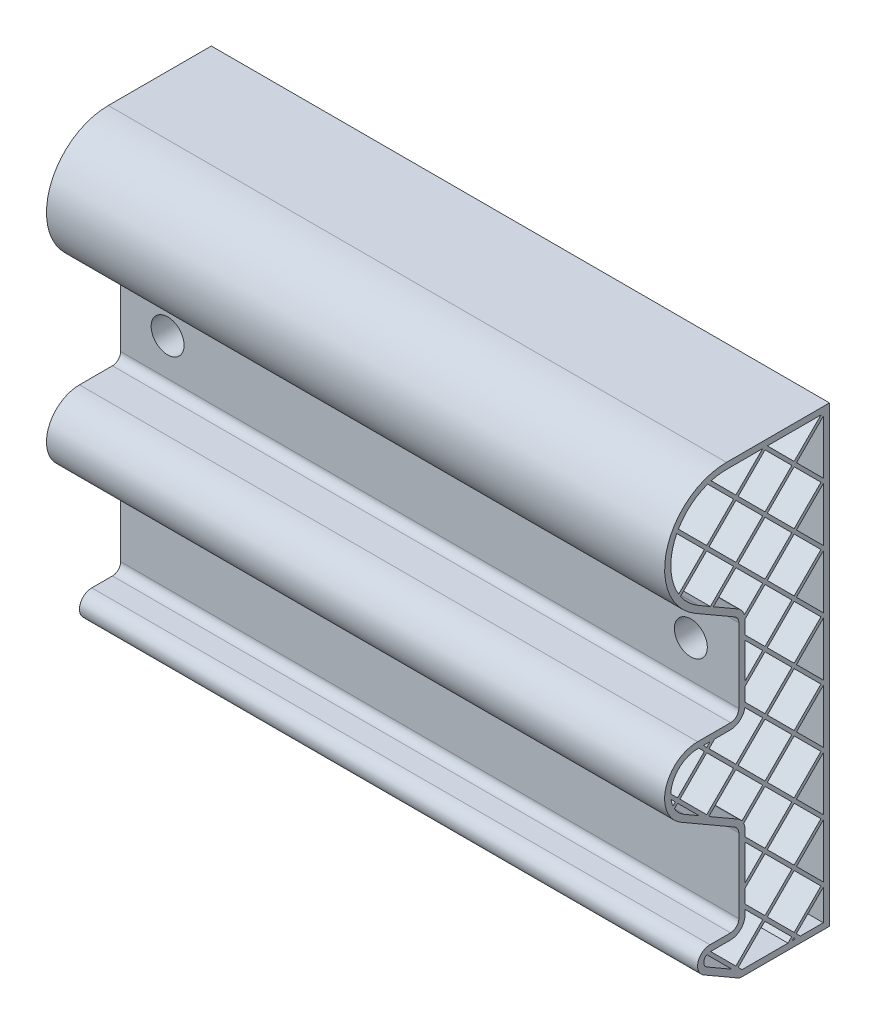
from build123d import *

# Parameters (mm, degrees)
SALIENTE_EXTRUIR1_DEPTH = 150
CORTAR_EXTRUIR1_DEPTH   = 151
CROQUIS6_R              = 5
SALIENTE_EXTRUIR2_DEPTH = 22
CROQUIS6_3_R            = 5
SALIENTE_EXTRUIR3_DEPTH = 22
CROQUIS7_R              = 2.5
CROQUIS7_R_2            = 2.567013522
CORTAR_EXTRUIR2_DEPTH   = 22
CROQUIS8_R              = 4
CORTAR_EXTRUIR3_DEPTH   = 7
CORTAR_EXTRUIR4_DEPTH   = 0.5


with BuildPart() as part:
    # Croquis1 → Saliente-Extruir1 (new body)
    with BuildSketch(Plane(origin=(0, 0, 0), x_dir=(0, 0, -1), z_dir=(1, 0, 0))):
        with BuildLine():
            Line((0, 0), (-21.253866082, 0))
            ThreePointArc((-21.253866082, 0), (-21.771504172, 0.068148347), (-22.253866082, 0.267949192))
            Line((-22.253866082, 0.267949192), (-30.5, 5.02885683))
            ThreePointArc((-30.5, 5.02885683), (-31.897777479, 8.403390176), (-29, 10.626933041))
            Line((-29, 10.626933041), (-24, 10.626933041))
            ThreePointArc((-24, 10.626933041), (-22.585786438, 11.212719479), (-22, 12.626933041))
            Line((-22, 12.626933041), (-22, 30.626933041))
            ThreePointArc((-22, 30.626933041), (-22.267949192, 31.626933041), (-23, 32.358983849))
            Line((-23, 32.358983849), (-36, 39.864537348))
            ThreePointArc((-36, 39.864537348), (-39.72740661, 48.863292939), (-32, 54.792740578))
            Line((-32, 54.792740578), (-24, 54.792740578))
            ThreePointArc((-24, 54.792740578), (-22.585786438, 55.378527016), (-22, 56.792740578))
            Line((-22, 56.792740578), (-22, 74.792740578))
            ThreePointArc((-22, 74.792740578), (-22.267949192, 75.792740578), (-23, 76.524791386))
            Line((-23, 76.524791386), (-32.5, 82.009618943))
            ThreePointArc((-32.5, 82.009618943), (-39.488887394, 98.882285677), (-25, 110))
            Line((-25, 110), (0, 110))
            Line((0, 110), (0, 0))
        make_face()
    extrude(amount=SALIENTE_EXTRUIR1_DEPTH)

    # Croquis5 → Cortar-Extruir1 (cut, through all)
    with BuildSketch(Plane(origin=(150, 0, 0), x_dir=(0, 0, -1), z_dir=(1, 0, 0))):
        with BuildLine():
            Line((-29.75, 6.327894935), (-23.652281634, 2.807375595))
            Line((-23.652281634, 2.807375595), (-29.763178762, 8.918272724))
            ThreePointArc((-29.763178762, 8.918272724), (-30.499980588, 7.619301765), (-29.75, 6.327894935))
        make_face()
        with BuildLine():
            Line((-20.5, 30.626933041), (-20.5, 29.070736059))
            Line((-20.5, 29.070736059), (-15.642135624, 24.212871683))
            Line((-15.642135624, 24.212871683), (-9.136753237, 30.718254069))
            Line((-9.136753237, 30.718254069), (-15.642135624, 37.223636456))
            Line((-15.642135624, 37.223636456), (-20.80650404, 32.059268041))
            ThreePointArc((-20.80650404, 32.059268041), (-20.577483684, 31.359314137), (-20.5, 30.626933041))
        make_face()
        Polygon((-10.070736059, 1.5), (-9.171921728, 2.398814331), (-15.677304115, 8.904196718), (-22.147518011, 2.433982822), (-21.213535189, 1.5), align=None)
        with BuildLine():
            Line((-22.713203436, 2.999668247), (-16.207821049, 9.505050634))
            Line((-16.207821049, 9.505050634), (-20.5, 13.797229585))
            Line((-20.5, 13.797229585), (-20.5, 12.626933041))
            ThreePointArc((-20.5, 12.626933041), (-21.525126266, 10.152059307), (-24, 9.126933041))
            Line((-24, 9.126933041), (-28.84046823, 9.126933041))
            Line((-28.84046823, 9.126933041), (-22.713203436, 2.999668247))
        make_face()
        Polygon((-7.071399565, 1.5), (-8.049919447, 2.478519882), (-1.5, 8.939365209), (-1.5, 1.5), align=None)
        Polygon((-2.065685425, 9.505050634), (-8.571067812, 16.010433021), (-15.076450199, 9.505050634), (-8.571067812, 2.999668247), align=None)
        Polygon((-1.5, 10.070736059), (-8.005382387, 16.576118446), (-1.5, 23.081500833), align=None)
        Polygon((-2.065685425, 23.647186258), (-8.571067812, 30.152568645), (-15.076450199, 23.647186258), (-8.571067812, 17.141803871), align=None)
        Polygon((-1.5, 24.212871683), (-8.005382387, 30.718254069), (-1.5, 37.223636456), align=None)
        Polygon((-2.065685425, 37.789321881), (-8.571067812, 44.294704268), (-15.076450199, 37.789321881), (-8.571067812, 31.283939494), align=None)
        Polygon((-1.5, 38.355007306), (-8.005382387, 44.860389693), (-1.5, 51.36577208), align=None)
        Polygon((-29.784271247, 38.355007306), (-23.278888861, 44.860389693), (-29.784271247, 51.36577208), (-36.289653634, 44.860389693), align=None)
        with BuildLine():
            Line((-29.218585823, 37.789321881), (-22.713203436, 44.294704268))
            Line((-22.713203436, 44.294704268), (-16.207821049, 37.789321881))
            Line((-16.207821049, 37.789321881), (-21.230346076, 32.766796854))
            ThreePointArc((-21.230346076, 32.766796854), (-21.696657115, 33.262196132), (-22.25, 33.658021954))
            Line((-22.25, 33.658021954), (-28.963090506, 37.533826565))
            Line((-28.963090506, 37.533826565), (-29.218585823, 37.789321881))
        make_face()
        Polygon((-1.5, 52.49714293), (-8.005382387, 59.002525317), (-1.5, 65.507907704), align=None)
        Polygon((-2.065685425, 51.931457505), (-8.571067812, 58.436839892), (-15.076450199, 51.931457505), (-8.571067812, 45.426075118), align=None)
        with BuildLine():
            Line((-37.621148526, 43.528894802), (-36.855339059, 44.294704268))
            Line((-36.855339059, 44.294704268), (-31.639942678, 39.079307887))
            Line((-31.639942678, 39.079307887), (-35.25, 41.163575454))
            ThreePointArc((-35.25, 41.163575454), (-36.590534059, 42.190893443), (-37.621148526, 43.528894802))
        make_face()
        with BuildLine():
            Line((-37.996664295, 44.284749882), (-37.421024484, 44.860389693))
            Line((-37.421024484, 44.860389693), (-38.434760865, 45.874126074))
            ThreePointArc((-38.434760865, 45.874126074), (-38.266307689, 45.065491913), (-37.996664295, 44.284749882))
        make_face()
        Polygon((-20.5, 74.792178951), (-15.642135624, 79.650043328), (-9.136753237, 73.144660941), (-15.642135624, 66.639278554), (-20.5, 71.49714293), align=None)
        with BuildLine():
            Line((-20.642449535, 75.781100266), (-16.207821049, 80.215728753))
            Line((-16.207821049, 80.215728753), (-22.713203436, 86.721111139))
            Line((-22.713203436, 86.721111139), (-28.184309751, 81.250004824))
            Line((-28.184309751, 81.250004824), (-22.25, 77.823829492))
            ThreePointArc((-22.25, 77.823829492), (-21.249553925, 76.957237377), (-20.642449535, 75.781100266))
        make_face()
        Polygon((-1.5, 107.934314575), (-8.005382387, 101.428932188), (-1.5, 94.923549801), align=None)
        Polygon((-2.065685425, 108.5), (-8.571067812, 101.994617613), (-15.076450199, 108.5), align=None)
        Polygon((-15.642135624, 107.934314575), (-9.136753237, 101.428932188), (-15.642135624, 94.923549801), (-22.147518011, 101.428932188), align=None)
        with BuildLine():
            Line((-36.165178282, 87.411271917), (-29.784271247, 93.792178951))
            Line((-29.784271247, 93.792178951), (-23.278888861, 87.286796564))
            Line((-23.278888861, 87.286796564), (-28.901570129, 81.664115296))
            Line((-28.901570129, 81.664115296), (-31.75, 83.308657049))
            ThreePointArc((-31.75, 83.308657049), (-34.189464914, 85.110422932), (-36.165178282, 87.411271917))
        make_face()
        with BuildLine():
            Line((-36.605078302, 88.102742747), (-30.349956672, 94.357864376))
            Line((-30.349956672, 94.357864376), (-37.059638564, 101.067546268))
            ThreePointArc((-37.059638564, 101.067546268), (-38.491709998, 94.526965818), (-36.605078302, 88.102742747))
        make_face()
        with BuildLine():
            Line((-36.661739101, 101.801017655), (-29.784271247, 94.923549801))
            Line((-29.784271247, 94.923549801), (-23.278888861, 101.428932188))
            Line((-23.278888861, 101.428932188), (-29.557428651, 107.707471979))
            ThreePointArc((-29.557428651, 107.707471979), (-33.630579431, 105.380900668), (-36.661739101, 101.801017655))
        make_face()
        with BuildLine():
            Line((-28.701285342, 107.98269952), (-22.713203436, 101.994617613))
            Line((-22.713203436, 101.994617613), (-16.207821049, 108.5))
            Line((-16.207821049, 108.5), (-25, 108.5))
            ThreePointArc((-25, 108.5), (-26.868630044, 108.37004943), (-28.701285342, 107.98269952))
        make_face()
        Polygon((-22.713203436, 100.863246763), (-16.207821049, 94.357864376), (-22.713203436, 87.852481989), (-29.218585823, 94.357864376), align=None)
        Polygon((-15.076450199, 94.357864376), (-8.571067812, 87.852481989), (-2.065685425, 94.357864376), (-8.571067812, 100.863246763), align=None)
        Polygon((-15.642135624, 93.792178951), (-22.147518011, 87.286796564), (-15.642135624, 80.781414177), (-9.136753237, 87.286796564), align=None)
        Polygon((-8.005382387, 87.286796564), (-1.5, 80.781414177), (-1.5, 93.792178951), align=None)
        Polygon((-8.571067812, 86.721111139), (-2.065685425, 80.215728753), (-8.571067812, 73.710346366), (-15.076450199, 80.215728753), align=None)
        Polygon((-8.571067812, 72.578975516), (-2.065685425, 66.073593129), (-8.571067812, 59.568210742), (-15.076450199, 66.073593129), align=None)
        Polygon((-8.005382387, 73.144660941), (-1.5, 66.639278554), (-1.5, 79.650043328), align=None)
        Polygon((-16.207821049, 66.073593129), (-20.5, 70.36577208), (-20.5, 61.781414177), align=None)
        Polygon((-9.136753237, 59.002525317), (-15.642135624, 65.507907704), (-20.5, 60.650043328), (-20.5, 57.355007306), (-15.642135624, 52.49714293), align=None)
        with BuildLine():
            Line((-16.207821049, 51.931457505), (-20.540194436, 56.263830892))
            ThreePointArc((-20.540194436, 56.263830892), (-21.719778947, 54.1374455), (-24, 53.292740578))
            Line((-24, 53.292740578), (-27.857302749, 53.292740578))
            Line((-27.857302749, 53.292740578), (-29.218585823, 51.931457505))
            Line((-29.218585823, 51.931457505), (-22.713203436, 45.426075118))
            Line((-22.713203436, 45.426075118), (-16.207821049, 51.931457505))
        make_face()
        Polygon((-29.784271247, 52.49714293), (-28.988673599, 53.292740578), (-30.579868896, 53.292740578), align=None)
        with BuildLine():
            Line((-30.349956672, 51.931457505), (-31.711239746, 53.292740578))
            Line((-31.711239746, 53.292740578), (-32, 53.292740578))
            ThreePointArc((-32, 53.292740578), (-36.498895226, 51.484216012), (-38.494294287, 47.065030346))
            Line((-38.494294287, 47.065030346), (-36.855339059, 45.426075118))
            Line((-36.855339059, 45.426075118), (-30.349956672, 51.931457505))
        make_face()
        Polygon((-15.642135624, 38.355007306), (-9.136753237, 44.860389693), (-15.642135624, 51.36577208), (-22.147518011, 44.860389693), align=None)
        Polygon((-16.207821049, 23.647186258), (-20.5, 27.939365209), (-20.5, 19.355007306), align=None)
        Polygon((-9.136753237, 16.576118446), (-15.642135624, 23.081500833), (-20.5, 18.223636456), (-20.5, 14.928600435), (-15.642135624, 10.070736059), align=None)
        Polygon((-8.654886921, 1.881779524), (-8.273107397, 1.5), (-9.041929948, 1.5), align=None)
    extrude(amount=-CORTAR_EXTRUIR1_DEPTH, mode=Mode.SUBTRACT)

    # Croquis6 → Saliente-Extruir2 (add)
    with BuildSketch(Plane.XY.offset(22)):
        with Locations((11.391749044, 65.792740578)):
            Circle(CROQUIS6_R)
    extrude(amount=-SALIENTE_EXTRUIR2_DEPTH)

    # Croquis6_3 → Saliente-Extruir3 (add)
    with BuildSketch(Plane.XY.offset(22)):
        with Locations((138.359294984, 65.792740578)):
            Circle(CROQUIS6_3_R)
    extrude(amount=-SALIENTE_EXTRUIR3_DEPTH)

    # Croquis7 → Cortar-Extruir2 (cut)
    with BuildSketch(Plane.XY.offset(22)):
        with Locations((11.391749044, 65.792740578)):
            Circle(CROQUIS7_R)
        with Locations((138.359294984, 65.792740578)):
            Circle(CROQUIS7_R_2)
    extrude(amount=-CORTAR_EXTRUIR2_DEPTH, mode=Mode.SUBTRACT)

    # Croquis8 → Cortar-Extruir3 (cut)
    with BuildSketch(Plane.XY.offset(22)):
        with Locations((11.391749044, 65.792740578)):
            Circle(CROQUIS8_R)
        with Locations((138.359294984, 65.792740578)):
            Circle(CROQUIS8_R)
    extrude(amount=-CORTAR_EXTRUIR3_DEPTH, mode=Mode.SUBTRACT)

    # Croquis9 → Cortar-Extruir4 (cut)
    with BuildSketch(Plane(origin=(0, 0, 0), x_dir=(-1, 0, 0), z_dir=(0, 0, -1))):
        Polygon((-146.236552998, 9.933390721), (-145.625976075, 9.933390721), (-143.509309408, 4.929204022), (-141.392642741, 9.933390721), (-140.782065818, 9.933390721), (-143.46860428, 3.583390721), (-143.550014536, 3.583390721), align=None)
        with BuildLine():
            Line((-139.398091459, 7.979544567), (-139.967963254, 7.979544567))
            add(Edge.make_bspline(
                [(-139.967963254, 7.979544567), (-139.964249134, 8.055147464), (-139.9569547, 8.20362954), (-139.922794804, 8.420117199), (-139.873916355, 8.627045191), (-139.804807574, 8.822752035), (-139.71898047, 9.008968156), (-139.616055992, 9.184953899), (-139.494147149, 9.350037913), (-139.35588636, 9.502689814), (-139.205720401, 9.642730121), (-139.04369391, 9.763661776), (-138.873432218, 9.865838123), (-138.69545188, 9.951256947), (-138.507744858, 10.015373525), (-138.31201453, 10.062947071), (-138.107400954, 10.09156987), (-137.967991199, 10.094646509), (-137.897089857, 10.096211234)],
                knots=[0, 0, 0, 0, 0.000226936, 0.000445697, 0.000656417, 0.000864005, 0.001067188, 0.001270734, 0.001474522, 0.00168168, 0.001887816, 0.002089561, 0.002286989, 0.002482721, 0.002680645, 0.002880876, 0.003086317, 0.003298933, 0.003298933, 0.003298933, 0.003298933], degree=3))
            add(Edge.make_bspline(
                [(-137.897089857, 10.096211234), (-137.827461065, 10.094581177), (-137.690642977, 10.091378174), (-137.490959037, 10.063871735), (-137.300863088, 10.020790448), (-137.120726712, 9.960346764), (-136.951987137, 9.879095017), (-136.793376756, 9.781490911), (-136.643007285, 9.66860636), (-136.507649264, 9.535703013), (-136.383356034, 9.393821544), (-136.276127657, 9.242350633), (-136.184300918, 9.085906072), (-136.107760413, 8.923294906), (-136.051415704, 8.75298604), (-136.008638098, 8.577458972), (-135.984458361, 8.394896815), (-135.980747379, 8.271332064), (-135.97886069, 8.208510913)],
                knots=[0, 0, 0, 0, 0.000208804, 0.000410292, 0.000603457, 0.000792922, 0.000978974, 0.001163976, 0.001350969, 0.00154169, 0.001731956, 0.001916203, 0.002097498, 0.002275629, 0.002454231, 0.002634721, 0.00281696, 0.003005431, 0.003005431, 0.003005431, 0.003005431], degree=3))
            add(Edge.make_bspline(
                [(-135.97886069, 8.208510913), (-135.981932753, 8.120068414), (-135.988022968, 7.944735455), (-136.040119051, 7.687079918), (-136.121483435, 7.437446143), (-136.219450068, 7.236537038), (-136.318278645, 7.074641985), (-136.407337409, 6.941348763), (-136.511594995, 6.797828842), (-136.632568841, 6.644562816), (-136.767756481, 6.480350174), (-136.918382406, 6.305290116), (-137.085520723, 6.121191334), (-137.202829717, 5.995451171), (-137.263616299, 5.930295769)],
                knots=[0, 0, 0, 0, 0.0002651, 0.000525547, 0.000785404, 0.001051089, 0.001193761, 0.001354284, 0.001531883, 0.001725783, 0.001939958, 0.002169957, 0.002418529, 0.002685853, 0.002685853, 0.002685853, 0.002685853], degree=3))
            Line((-137.263616299, 5.930295769), (-138.852388334, 4.234672772))
            Line((-138.852388334, 4.234672772), (-135.897450434, 4.234672772))
            Line((-135.897450434, 4.234672772), (-135.897450434, 3.583390721))
            Line((-135.897450434, 3.583390721), (-140.212194023, 3.583390721))
            Line((-140.212194023, 3.583390721), (-137.749533767, 6.211415561))
            add(Edge.make_bspline(
                [(-137.749533767, 6.211415561), (-137.689575458, 6.274005346), (-137.574407817, 6.394227513), (-137.411516571, 6.569746883), (-137.265214406, 6.732578193), (-137.13455428, 6.882413788), (-137.022370634, 7.021445347), (-136.922816728, 7.145170023), (-136.843050584, 7.259024526), (-136.756481223, 7.390996783), (-136.672635857, 7.552127701), (-136.600586297, 7.749038823), (-136.556653643, 7.951743981), (-136.551383442, 8.088726248), (-136.548732485, 8.157629503)],
                knots=[0, 0, 0, 0, 0.000260022, 0.000499448, 0.000718331, 0.000916736, 0.001095736, 0.001254271, 0.001392976, 0.001512588, 0.001727648, 0.001936091, 0.002140165, 0.002346709, 0.002346709, 0.002346709, 0.002346709], degree=3))
            add(Edge.make_bspline(
                [(-136.548732485, 8.157629503), (-136.549885903, 8.200957183), (-136.552159069, 8.28634772), (-136.572220891, 8.411543883), (-136.602538524, 8.532311474), (-136.645982064, 8.649021969), (-136.703325721, 8.760501937), (-136.773127424, 8.86688708), (-136.853663682, 8.96973706), (-136.946829556, 9.066172329), (-137.049176171, 9.154493945), (-137.157297167, 9.232733357), (-137.27168807, 9.298118601), (-137.391866577, 9.351718946), (-137.517497643, 9.393765709), (-137.648824252, 9.42290056), (-137.785483539, 9.441193066), (-137.878798596, 9.443668064), (-137.926346668, 9.444929183)],
                knots=[0, 0, 0, 0, 0.000129903, 0.000256015, 0.000379422, 0.000502993, 0.000628718, 0.000754676, 0.000884205, 0.001020051, 0.00115623, 0.001289314, 0.001419795, 0.001550759, 0.001683503, 0.001816508, 0.001953776, 0.002096386, 0.002096386, 0.002096386, 0.002096386], degree=3))
            add(Edge.make_bspline(
                [(-137.926346668, 9.444929183), (-137.976005179, 9.44363191), (-138.073526295, 9.44108428), (-138.216707969, 9.423263161), (-138.353297879, 9.392518565), (-138.483639617, 9.350469456), (-138.607953723, 9.297023232), (-138.725635632, 9.230453923), (-138.836421159, 9.151018157), (-138.940518566, 9.060956005), (-139.036428928, 8.960684786), (-139.120696831, 8.84890671), (-139.194327828, 8.727662685), (-139.258570295, 8.597279857), (-139.310741333, 8.456575142), (-139.350606905, 8.306048021), (-139.382151613, 8.146352086), (-139.392689929, 8.036070575), (-139.398091459, 7.979544567)],
                knots=[0, 0, 0, 0, 0.000148964, 0.000292541, 0.00043203, 0.000568399, 0.000702856, 0.000837284, 0.000973177, 0.00111115, 0.001249715, 0.001388623, 0.001530208, 0.001674706, 0.001824033, 0.001979555, 0.002141464, 0.002311717, 0.002311717, 0.002311717, 0.002311717], degree=3))
        make_face()
    extrude(amount=-CORTAR_EXTRUIR4_DEPTH, mode=Mode.SUBTRACT)


solid = part.part
